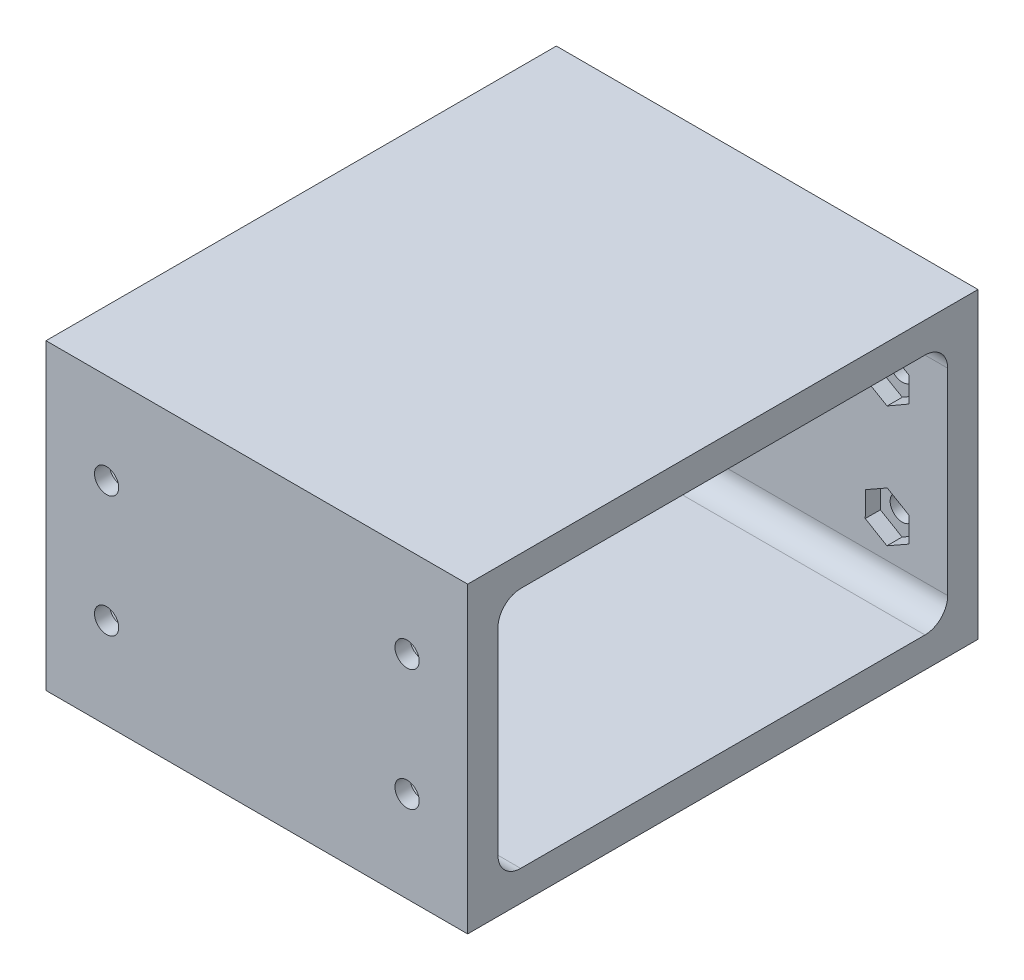
from build123d import *

# Parameters (mm, degrees)
SKETCH1_W               = 55.67262225
SKETCH1_H               = 40
BOSS_EXTRUDE1_DEPTH     = 4
SKETCH2_W               = 55.67262225
SKETCH2_H               = 4
BOSS_EXTRUDE2_DEPTH     = 63.38
SKETCH3_W               = 55.67262225
SKETCH3_H               = 40
BOSS_EXTRUDE3_DEPTH     = 4
SKETCH4_R               = 1.6
CUT_EXTRUDE1_DEPTH      = 64.38
CUT_EXTRUDE1_DEPTH_BACK = 5
CUT_EXTRUDE2_START      = -2
CUT_EXTRUDE2_DEPTH      = 63.38
FILLET1_R               = 3


with BuildPart() as part:
    # Sketch1 → Boss-Extrude1 (new body)
    with BuildSketch(Plane.XY):
        with Locations((-256.769960814, -1.19608299)):
            Rectangle(SKETCH1_W, SKETCH1_H)
    extrude(amount=BOSS_EXTRUDE1_DEPTH)

    # Sketch2 → Boss-Extrude2 (add)
    with BuildSketch(Plane.XY.offset(4)):
        with Locations((-256.769960814, -19.19608299)):
            Rectangle(SKETCH2_W, SKETCH2_H)
        with Locations((-256.769960814, 16.80391701)):
            Rectangle(SKETCH2_W, SKETCH2_H)
    extrude(amount=BOSS_EXTRUDE2_DEPTH)

    # Sketch3 → Boss-Extrude3 (add)
    with BuildSketch(Plane(origin=(0, 0, 67.38), x_dir=(-1, 0, 0), z_dir=(0, 0, -1))):
        with Locations((256.769960814, -1.19608299)):
            Rectangle(SKETCH3_W, SKETCH3_H)
    extrude(amount=BOSS_EXTRUDE3_DEPTH)

    # Sketch4 → Cut-Extrude1 (cut, two sides)
    with BuildSketch(Plane.XY.offset(4)) as cut_extrude1_sk:
        with Locations((-276.606271939, -9.19608299)):
            Circle(SKETCH4_R)
        with Locations((-276.606271939, 6.80391701)):
            Circle(SKETCH4_R)
        with Locations((-236.933649689, 6.80391701)):
            Circle(SKETCH4_R)
        with Locations((-236.933649689, -9.19608299)):
            Circle(SKETCH4_R)
    extrude(amount=CUT_EXTRUDE1_DEPTH, mode=Mode.SUBTRACT)
    extrude(cut_extrude1_sk.sketch, amount=-CUT_EXTRUDE1_DEPTH_BACK, mode=Mode.SUBTRACT)

    # Sketch5 → Cut-Extrude2 (cut)
    with BuildSketch(Plane.XY.offset(4).offset(CUT_EXTRUDE2_START)):
        Polygon((-276.602416628, -5.876321181), (-279.479342345, -7.532863288), (-279.483197655, -10.852625098), (-276.610127249, -12.515844799), (-273.733201533, -10.859302692), (-273.729346222, -7.539540882), align=None)
        Polygon((-276.606181369, 10.123681057), (-279.481226653, 8.463877469), (-279.481317222, 5.144113422), (-276.606362508, 3.484152963), (-273.731317224, 5.143956551), (-273.731226655, 8.463720598), align=None)
        Polygon((-236.907079951, -5.876425269), (-239.795272738, -7.513244061), (-239.821842476, -10.832901782), (-236.960219427, -12.515740711), (-234.07202664, -10.878921919), (-234.045456902, -7.559264198), align=None)
        Polygon((-236.933649689, 10.123681058), (-239.808649689, 8.463799034), (-239.808649689, 5.144034986), (-236.933649689, 3.484152962), (-234.058649689, 5.144034986), (-234.058649689, 8.463799034), align=None)
    extrude(amount=CUT_EXTRUDE2_DEPTH, mode=Mode.SUBTRACT)

    # Fillet1
    fillet1_edges = [part.edges().sort_by_distance(p)[0] for p in [
        (-256.769960814, -17.19608299, 4),
        (-256.769960814, 14.80391701, 4),
        (-256.769960814, -17.19608299, 63.38),
        (-256.769960814, 14.80391701, 63.38),
    ]]
    fillet(fillet1_edges, radius=FILLET1_R)


solid = part.part
